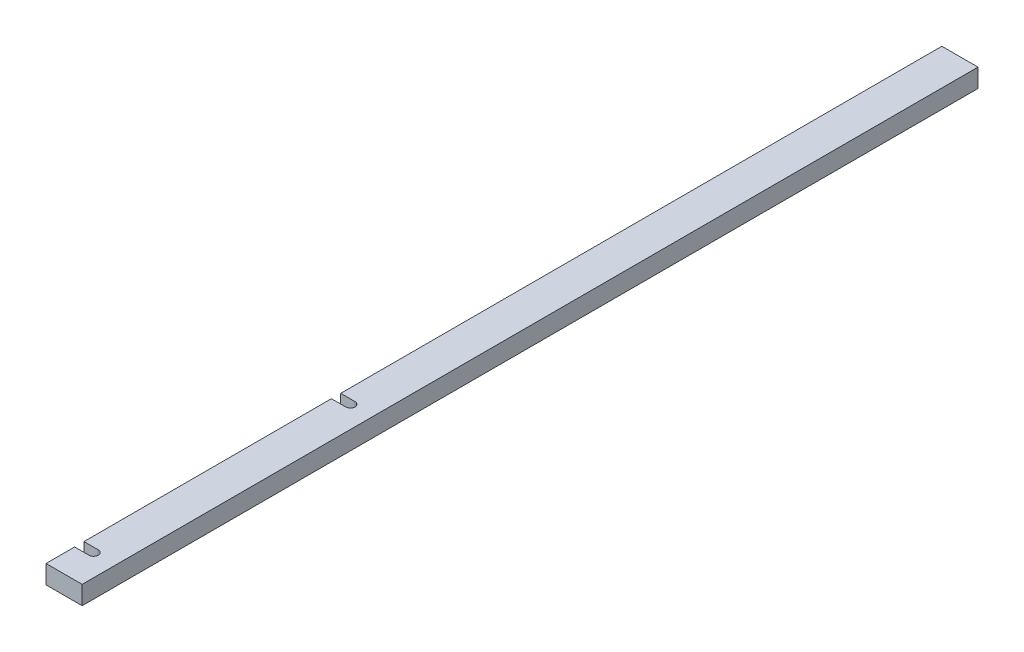
from build123d import *

# Parameters (mm, degrees)
SKETCH1_W           = 38
SKETCH1_H           = 19.5
BOSS_EXTRUDE1_DEPTH = 942
CUT_EXTRUDE1_DEPTH  = 61


with BuildPart() as part:
    # Sketch1 → Boss-Extrude1 (new body)
    with BuildSketch(Plane.XY):
        with Locations((-7.080898876, 0.350561798)):
            Rectangle(SKETCH1_W, SKETCH1_H)
    extrude(amount=BOSS_EXTRUDE1_DEPTH)

    # Sketch2 → Cut-Extrude1 (cut)
    with BuildSketch(Plane.XZ.offset(9.399438202)):
        with BuildLine():
            Line((-11.080898876, 911.9), (-32.643906923, 911.9))
            Line((-32.643906923, 911.9), (-32.643906923, 902.1))
            Line((-32.643906923, 902.1), (-11.080898876, 902.1))
            ThreePointArc((-11.080898876, 902.1), (-6.180898876, 907), (-11.080898876, 911.9))
        make_face()
        with BuildLine():
            Line((-11.080898876, 641.9), (-28.706990063, 641.9))
            Line((-28.706990063, 641.9), (-28.706990063, 632.1))
            Line((-28.706990063, 632.1), (-11.080898876, 632.1))
            ThreePointArc((-11.080898876, 632.1), (-6.180898876, 637), (-11.080898876, 641.9))
        make_face()
    extrude(amount=-CUT_EXTRUDE1_DEPTH, mode=Mode.SUBTRACT)


solid = part.part
